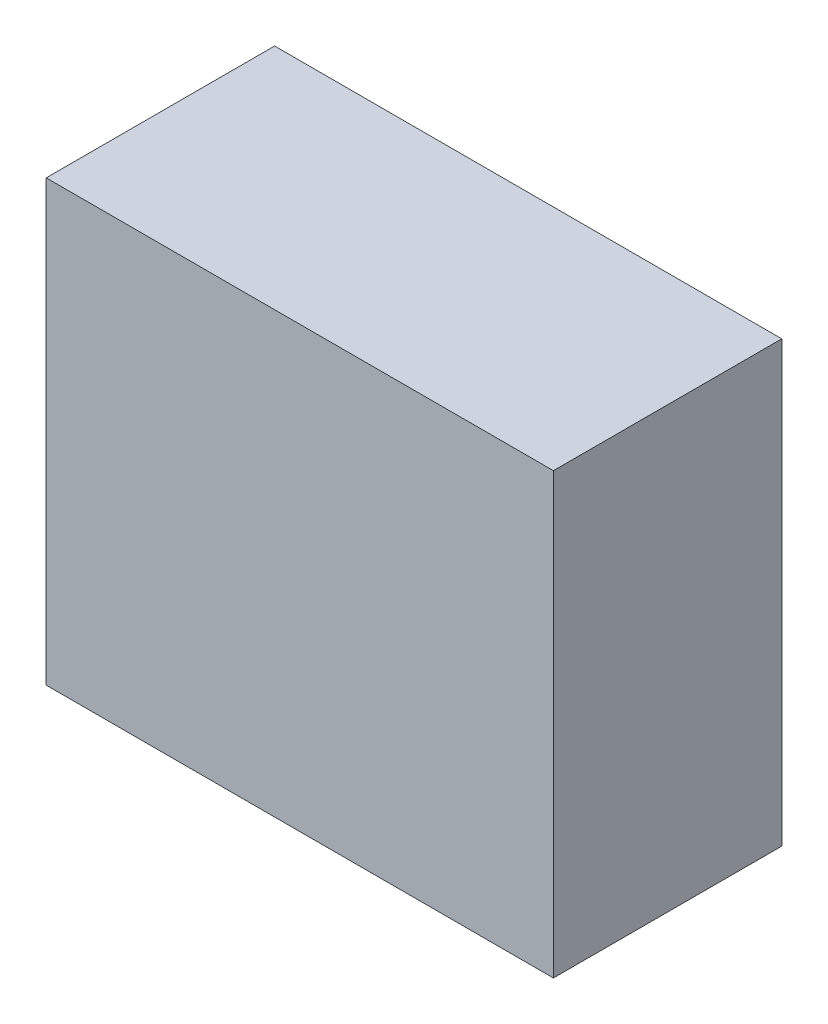
from build123d import *

# Parameters (mm, degrees)
SKETCH1_W           = 44.45
SKETCH1_H           = 20.0152
BOSS_EXTRUDE1_DEPTH = 38.5064


with BuildPart() as part:
    # Sketch1 → Boss-Extrude1 (new body)
    with BuildSketch(Plane(origin=(0, 0, 0), x_dir=(1, 0, 0), z_dir=(0, 1, 0))):
        Rectangle(SKETCH1_W, SKETCH1_H)
    extrude(amount=BOSS_EXTRUDE1_DEPTH)


solid = part.part
